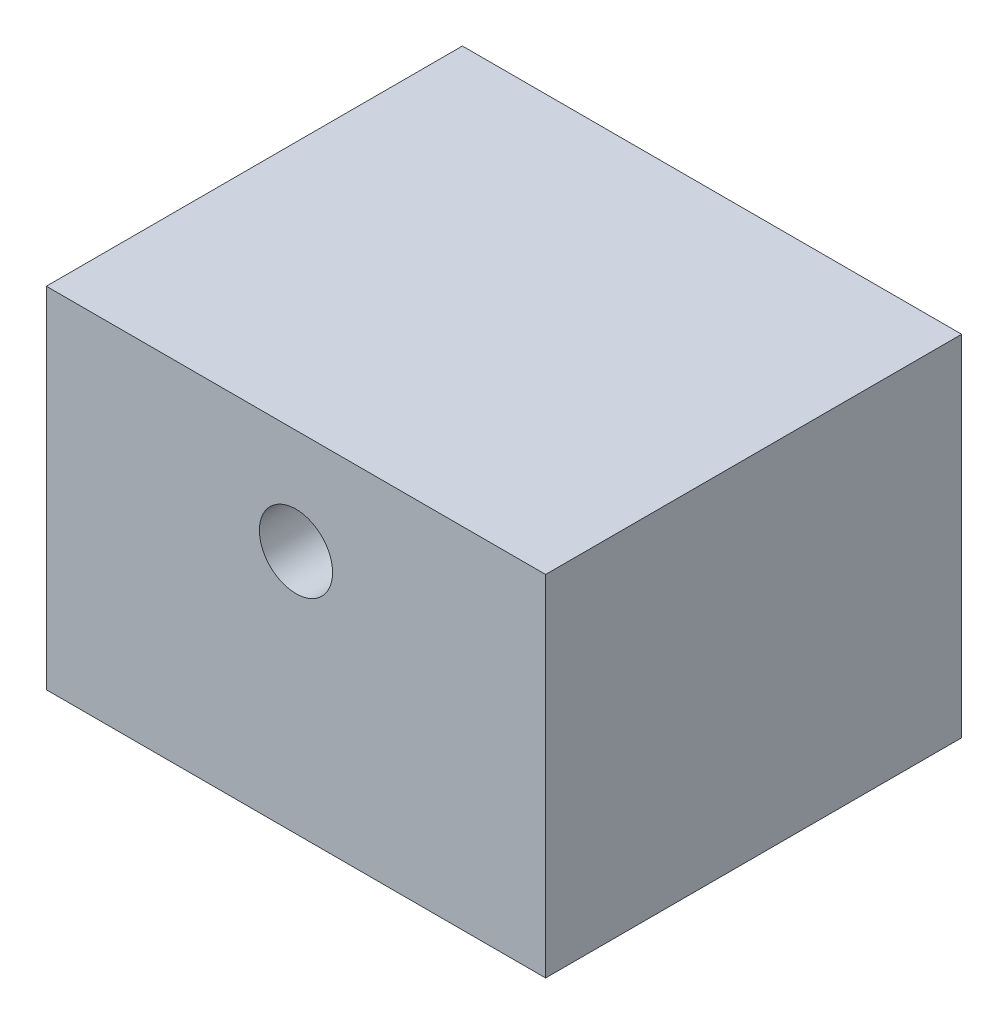
from build123d import *

# Parameters (mm, degrees)
SKETCH1_W           = 30
SKETCH1_H           = 21
SKETCH1_R           = 2.2
BOSS_EXTRUDE1_DEPTH = 12.5


with BuildPart() as part:
    # Sketch1 → Boss-Extrude1 (new body, symmetric)
    with BuildSketch(Plane.XY):
        with Locations((15, 10.5)):
            Rectangle(SKETCH1_W, SKETCH1_H)
        with Locations((15, 14.7)):
            Circle(SKETCH1_R, mode=Mode.SUBTRACT)
    extrude(amount=BOSS_EXTRUDE1_DEPTH, both=True)


solid = part.part
